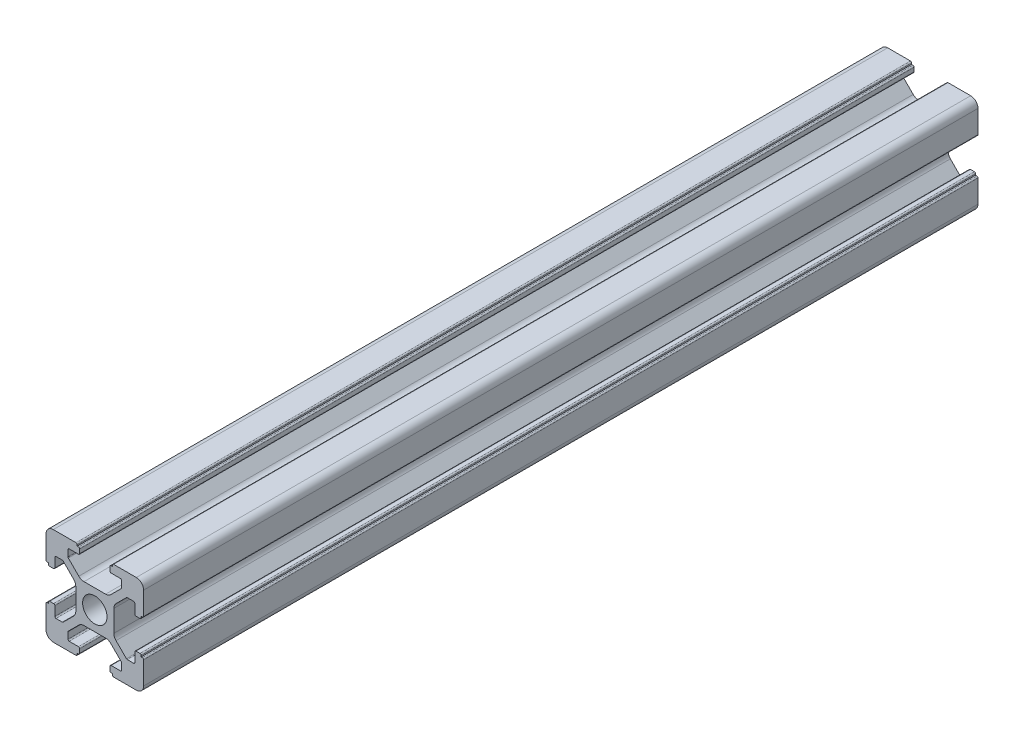
from build123d import *

# Parameters (mm, degrees)
SKETCH_1_R      = 2.5
EXTRUDE_1_DEPTH = 171


with BuildPart() as part:
    # 草图1 → 凸台-拉伸1 (new body)
    with BuildSketch(Plane.XY):
        with BuildLine():
            Line((-8.502261885, -10.002261885), (-3.85, -10.002261885))
            ThreePointArc((-3.85, -10.002261885), (-3.673223305, -9.929038581), (-3.6, -9.752261885))
            Line((-3.6, -9.752261885), (-3.6, -9.502261885))
            Line((-3.6, -9.502261885), (-3.35, -9.502261885))
            ThreePointArc((-3.35, -9.502261885), (-3.173223305, -9.429038581), (-3.1, -9.252261885))
            Line((-3.1, -9.252261885), (-3.1, -8.45))
            ThreePointArc((-3.1, -8.45), (-3.173223305, -8.273223305), (-3.35, -8.2))
            Line((-3.35, -8.2), (-5.25, -8.2))
            ThreePointArc((-5.25, -8.2), (-5.426776695, -8.126776695), (-5.5, -7.95))
            Line((-5.5, -7.95), (-5.5, -6.664213562))
            ThreePointArc((-5.5, -6.664213562), (-5.480969883, -6.568542704), (-5.426776695, -6.487436867))
            Line((-5.426776695, -6.487436867), (-3.278679656, -4.339339828))
            ThreePointArc((-3.278679656, -4.339339828), (-2.792044633, -4.014180701), (-2.218019485, -3.9))
            Line((-2.218019485, -3.9), (2.218019485, -3.9))
            ThreePointArc((2.218019485, -3.9), (2.792044633, -4.014180701), (3.278679656, -4.339339828))
            Line((3.278679656, -4.339339828), (5.426776695, -6.487436867))
            ThreePointArc((5.426776695, -6.487436867), (5.480969883, -6.568542704), (5.5, -6.664213562))
            Line((5.5, -6.664213562), (5.5, -7.95))
            ThreePointArc((5.5, -7.95), (5.426776695, -8.126776695), (5.25, -8.2))
            Line((5.25, -8.2), (3.35, -8.2))
            ThreePointArc((3.35, -8.2), (3.173223305, -8.273223305), (3.1, -8.45))
            Line((3.1, -8.45), (3.1, -9.252261885))
            ThreePointArc((3.1, -9.252261885), (3.173223305, -9.429038581), (3.35, -9.502261885))
            Line((3.35, -9.502261885), (3.6, -9.502261885))
            Line((3.6, -9.502261885), (3.6, -9.752261885))
            ThreePointArc((3.6, -9.752261885), (3.673223305, -9.929038581), (3.85, -10.002261885))
            Line((3.85, -10.002261885), (8.502261885, -10.002261885))
            ThreePointArc((8.502261885, -10.002261885), (9.562922057, -9.562922057), (10.002261885, -8.502261885))
            Line((10.002261885, -8.502261885), (10.002261885, -3.85))
            ThreePointArc((10.002261885, -3.85), (9.929038581, -3.673223305), (9.752261885, -3.6))
            Line((9.752261885, -3.6), (9.502261885, -3.6))
            Line((9.502261885, -3.6), (9.502261885, -3.35))
            ThreePointArc((9.502261885, -3.35), (9.429038581, -3.173223305), (9.252261885, -3.1))
            Line((9.252261885, -3.1), (8.45, -3.1))
            ThreePointArc((8.45, -3.1), (8.273223305, -3.173223305), (8.2, -3.35))
            Line((8.2, -3.35), (8.2, -5.25))
            ThreePointArc((8.2, -5.25), (8.126776695, -5.426776695), (7.95, -5.5))
            Line((7.95, -5.5), (6.664213562, -5.5))
            ThreePointArc((6.664213562, -5.5), (6.568542704, -5.480969883), (6.487436867, -5.426776695))
            Line((6.487436867, -5.426776695), (4.339339828, -3.278679656))
            ThreePointArc((4.339339828, -3.278679656), (4.014180701, -2.792044633), (3.9, -2.218019485))
            Line((3.9, -2.218019485), (3.9, 2.218019485))
            ThreePointArc((3.9, 2.218019485), (4.014180701, 2.792044633), (4.339339828, 3.278679656))
            Line((4.339339828, 3.278679656), (6.487436867, 5.426776695))
            ThreePointArc((6.487436867, 5.426776695), (6.568542704, 5.480969883), (6.664213562, 5.5))
            Line((6.664213562, 5.5), (7.95, 5.5))
            ThreePointArc((7.95, 5.5), (8.126776695, 5.426776695), (8.2, 5.25))
            Line((8.2, 5.25), (8.2, 3.35))
            ThreePointArc((8.2, 3.35), (8.273223305, 3.173223305), (8.45, 3.1))
            Line((8.45, 3.1), (9.252261885, 3.1))
            ThreePointArc((9.252261885, 3.1), (9.429038581, 3.173223305), (9.502261885, 3.35))
            Line((9.502261885, 3.35), (9.502261885, 3.6))
            Line((9.502261885, 3.6), (9.752261885, 3.6))
            ThreePointArc((9.752261885, 3.6), (9.929038581, 3.673223305), (10.002261885, 3.85))
            Line((10.002261885, 3.85), (10.002261885, 8.502261885))
            ThreePointArc((10.002261885, 8.502261885), (9.562922057, 9.562922057), (8.502261885, 10.002261885))
            Line((8.502261885, 10.002261885), (3.85, 10.002261885))
            ThreePointArc((3.85, 10.002261885), (3.673223305, 9.929038581), (3.6, 9.752261885))
            Line((3.6, 9.752261885), (3.6, 9.502261885))
            Line((3.6, 9.502261885), (3.35, 9.502261885))
            ThreePointArc((3.35, 9.502261885), (3.173223305, 9.429038581), (3.1, 9.252261885))
            Line((3.1, 9.252261885), (3.1, 8.45))
            ThreePointArc((3.1, 8.45), (3.173223305, 8.273223305), (3.35, 8.2))
            Line((3.35, 8.2), (5.25, 8.2))
            ThreePointArc((5.25, 8.2), (5.426776695, 8.126776695), (5.5, 7.95))
            Line((5.5, 7.95), (5.5, 6.664213562))
            ThreePointArc((5.5, 6.664213562), (5.480969883, 6.568542704), (5.426776695, 6.487436867))
            Line((5.426776695, 6.487436867), (3.278679656, 4.339339828))
            ThreePointArc((3.278679656, 4.339339828), (2.792044633, 4.014180701), (2.218019485, 3.9))
            Line((2.218019485, 3.9), (-2.218019485, 3.9))
            ThreePointArc((-2.218019485, 3.9), (-2.792044633, 4.014180701), (-3.278679656, 4.339339828))
            Line((-3.278679656, 4.339339828), (-5.426776695, 6.487436867))
            ThreePointArc((-5.426776695, 6.487436867), (-5.480969883, 6.568542704), (-5.5, 6.664213562))
            Line((-5.5, 6.664213562), (-5.5, 7.95))
            ThreePointArc((-5.5, 7.95), (-5.426776695, 8.126776695), (-5.25, 8.2))
            Line((-5.25, 8.2), (-3.35, 8.2))
            ThreePointArc((-3.35, 8.2), (-3.173223305, 8.273223305), (-3.1, 8.45))
            Line((-3.1, 8.45), (-3.1, 9.252261885))
            ThreePointArc((-3.1, 9.252261885), (-3.173223305, 9.429038581), (-3.35, 9.502261885))
            Line((-3.35, 9.502261885), (-3.6, 9.502261885))
            Line((-3.6, 9.502261885), (-3.6, 9.752261885))
            ThreePointArc((-3.6, 9.752261885), (-3.673223305, 9.929038581), (-3.85, 10.002261885))
            Line((-3.85, 10.002261885), (-8.502261885, 10.002261885))
            ThreePointArc((-8.502261885, 10.002261885), (-9.562922057, 9.562922057), (-10.002261885, 8.502261885))
            Line((-10.002261885, 8.502261885), (-10.002261885, 3.85))
            ThreePointArc((-10.002261885, 3.85), (-9.929038581, 3.673223305), (-9.752261885, 3.6))
            Line((-9.752261885, 3.6), (-9.502261885, 3.6))
            Line((-9.502261885, 3.6), (-9.502261885, 3.35))
            ThreePointArc((-9.502261885, 3.35), (-9.429038581, 3.173223305), (-9.252261885, 3.1))
            Line((-9.252261885, 3.1), (-8.45, 3.1))
            ThreePointArc((-8.45, 3.1), (-8.273223305, 3.173223305), (-8.2, 3.35))
            Line((-8.2, 3.35), (-8.2, 5.25))
            ThreePointArc((-8.2, 5.25), (-8.126776695, 5.426776695), (-7.95, 5.5))
            Line((-7.95, 5.5), (-6.664213562, 5.5))
            ThreePointArc((-6.664213562, 5.5), (-6.568542704, 5.480969883), (-6.487436867, 5.426776695))
            Line((-6.487436867, 5.426776695), (-4.339339828, 3.278679656))
            ThreePointArc((-4.339339828, 3.278679656), (-4.014180701, 2.792044633), (-3.9, 2.218019485))
            Line((-3.9, 2.218019485), (-3.9, -2.218019485))
            ThreePointArc((-3.9, -2.218019485), (-4.014180701, -2.792044633), (-4.339339828, -3.278679656))
            Line((-4.339339828, -3.278679656), (-6.487436867, -5.426776695))
            ThreePointArc((-6.487436867, -5.426776695), (-6.568542704, -5.480969883), (-6.664213562, -5.5))
            Line((-6.664213562, -5.5), (-7.95, -5.5))
            ThreePointArc((-7.95, -5.5), (-8.126776695, -5.426776695), (-8.2, -5.25))
            Line((-8.2, -5.25), (-8.2, -3.35))
            ThreePointArc((-8.2, -3.35), (-8.273223305, -3.173223305), (-8.45, -3.1))
            Line((-8.45, -3.1), (-9.252261885, -3.1))
            ThreePointArc((-9.252261885, -3.1), (-9.429038581, -3.173223305), (-9.502261885, -3.35))
            Line((-9.502261885, -3.35), (-9.502261885, -3.6))
            Line((-9.502261885, -3.6), (-9.752261885, -3.6))
            ThreePointArc((-9.752261885, -3.6), (-9.929038581, -3.673223305), (-10.002261885, -3.85))
            Line((-10.002261885, -3.85), (-10.002261885, -8.502261885))
            ThreePointArc((-10.002261885, -8.502261885), (-9.562922057, -9.562922057), (-8.502261885, -10.002261885))
        make_face()
        Circle(SKETCH_1_R, mode=Mode.SUBTRACT)
    extrude(amount=EXTRUDE_1_DEPTH)


solid = part.part
